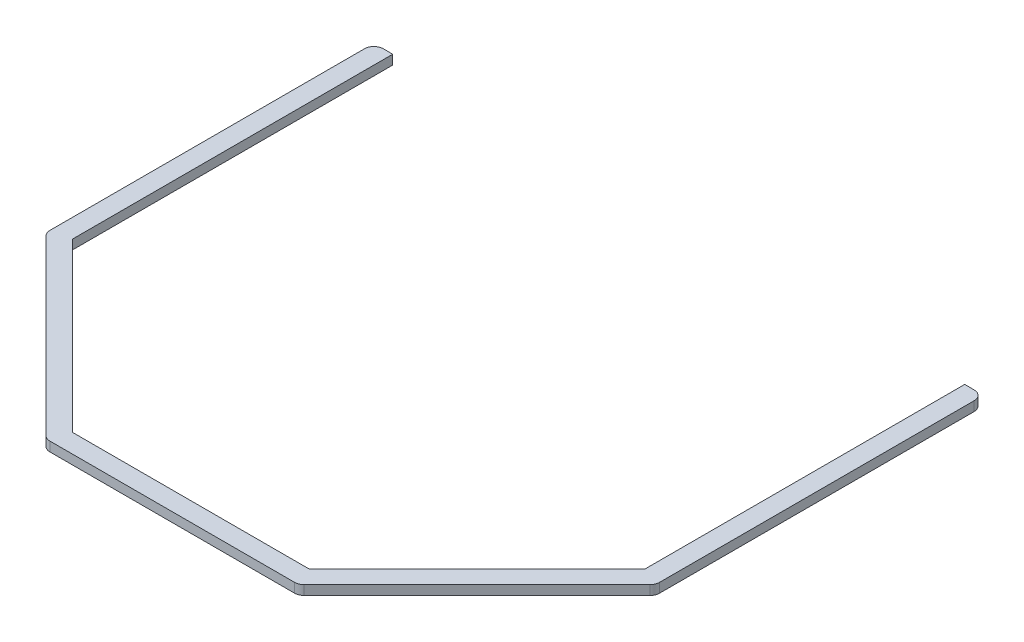
from build123d import *

# Parameters (mm, degrees)
BOSS_EXTRUDE1_DEPTH = 6.35


with BuildPart() as part:
    # Sketch1 → Boss-Extrude1 (new body)
    with BuildSketch(Plane(origin=(0, 0, 0), x_dir=(1, 0, 0), z_dir=(0, 1, 0))):
        with BuildLine():
            Line((-192.717689271, 135.886792847), (-192.717689271, -79.826280605))
            Line((-192.717689271, -79.826280605), (-79.826280605, -192.717689271))
            Line((-79.826280605, -192.717689271), (79.826280605, -192.717689271))
            Line((79.826280605, -192.717689271), (192.717689271, -79.826280605))
            Line((192.717689271, -79.826280605), (192.717689271, 135.886792847))
            Line((192.717689271, 135.886792847), (199.067689271, 135.886792847))
            ThreePointArc((199.067689271, 135.886792847), (203.557817332, 134.026920908), (205.417689271, 129.536792847))
            Line((205.417689271, 129.536792847), (205.417689271, 85.086792847))
            Line((205.417689271, 85.086792847), (205.417689271, -82.456536726))
            ThreePointArc((205.417689271, -82.456536726), (204.934324303, -84.886576522), (203.557817332, -86.946664787))
            Line((203.557817332, -86.946664787), (86.946664787, -203.557817332))
            ThreePointArc((86.946664787, -203.557817332), (84.886576522, -204.934324303), (82.456536726, -205.417689271))
            Line((82.456536726, -205.417689271), (-82.456536726, -205.417689271))
            ThreePointArc((-82.456536726, -205.417689271), (-84.886576522, -204.934324303), (-86.946664787, -203.557817332))
            Line((-86.946664787, -203.557817332), (-203.557817332, -86.946664787))
            ThreePointArc((-203.557817332, -86.946664787), (-204.934324303, -84.886576522), (-205.417689271, -82.456536726))
            Line((-205.417689271, -82.456536726), (-205.417689271, 85.086792847))
            Line((-205.417689271, 85.086792847), (-205.417689271, 129.536792847))
            ThreePointArc((-205.417689271, 129.536792847), (-203.557817332, 134.026920908), (-199.067689271, 135.886792847))
            Line((-199.067689271, 135.886792847), (-192.717689271, 135.886792847))
        make_face()
    extrude(amount=BOSS_EXTRUDE1_DEPTH)


solid = part.part
